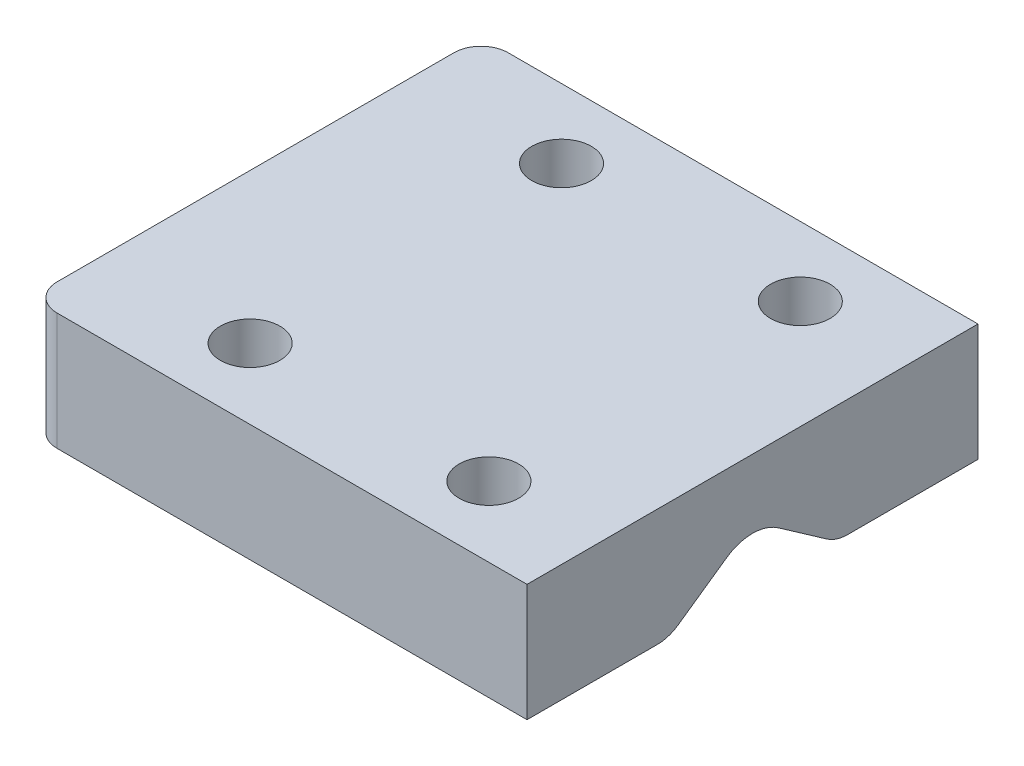
from build123d import *

# Parameters (mm, degrees)
SKETCH6_W          = 55.097235346
SKETCH6_H          = 50
MAIN_BODY_DEPTH    = 13
MAIN_HOLE_DEPTH    = 56.097235346
EXTERIOR_FILLET_R  = 3
SKETCH9_R          = 3.3
BOLT_HOLES_DEPTH   = 14
TOP_HOLE_FILLET_R  = 5
SIDE_HOLE_FILLET_R = 4


with BuildPart() as part:
    # Sketch6 → Main Body (new body)
    with BuildSketch(Plane(origin=(0, 68, 0), x_dir=(1, 0, 0), z_dir=(0, 1, 0))):
        with Locations((-0.048617673, 0)):
            Rectangle(SKETCH6_W, SKETCH6_H)
    extrude(amount=MAIN_BODY_DEPTH)

    # Sketch7 → Main Hole (cut, through all)
    with BuildSketch(Plane(origin=(27.5, 0, 0), x_dir=(0, 0, -1), z_dir=(1, 0, 0))):
        Polygon((0, 74.5), (-9.282962044, 68), (0, 61.5), (9.282962044, 68), align=None)
    extrude(amount=-MAIN_HOLE_DEPTH, mode=Mode.SUBTRACT)

    # Exterior Fillet
    exterior_fillet_edges = [part.edges().sort_by_distance(p)[0] for p in [
        (-27.597235346, 74.5, 25),
        (-27.597235346, 74.5, -25),
    ]]
    fillet(exterior_fillet_edges, radius=EXTERIOR_FILLET_R)

    # Sketch9 → Bolt Holes (cut, through all)
    with BuildSketch(Plane(origin=(0, 81, 0), x_dir=(1, 0, 0), z_dir=(0, 1, 0))):
        with Locations((15.473743703, -17.201232435)):
            Circle(SKETCH9_R)
        with Locations((-11, -17.201232435)):
            Circle(SKETCH9_R)
        with Locations((15.473743703, 17.324336932)):
            Circle(SKETCH9_R)
        with Locations((-11, 17.324336932)):
            Circle(SKETCH9_R)
    extrude(amount=-BOLT_HOLES_DEPTH, mode=Mode.SUBTRACT)

    # Top Hole Fillet
    top_hole_fillet_edges = [part.edges().sort_by_distance(p)[0] for p in [
        (-0.048617673, 74.5, 0),
    ]]
    fillet(top_hole_fillet_edges, radius=TOP_HOLE_FILLET_R)

    # Side Hole Fillet
    side_hole_fillet_edges = [part.edges().sort_by_distance(p)[0] for p in [
        (-0.048617673, 68, -9.282962044),
        (-0.048617673, 68, 9.282962044),
    ]]
    fillet(side_hole_fillet_edges, radius=SIDE_HOLE_FILLET_R)


solid = part.part
